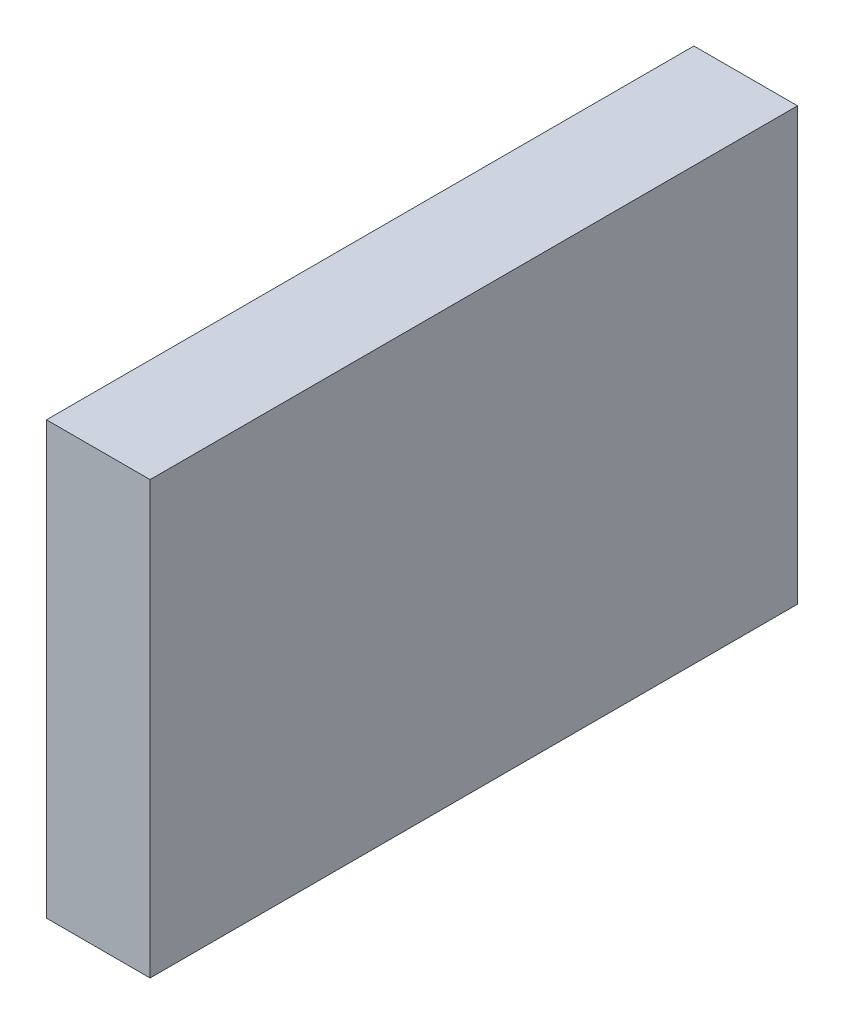
from build123d import *

# Parameters (mm, degrees)
SKETCH1_W           = 76.2
SKETCH1_H           = 50.8
BOSS_EXTRUDE1_DEPTH = 12.7
CHAMFER1_SIZE       = 0.508


with BuildPart() as part:
    # Sketch1 → Boss-Extrude1 (new body)
    with BuildSketch(Plane(origin=(0, 0, 0), x_dir=(0, 0, -1), z_dir=(1, 0, 0))):
        Rectangle(SKETCH1_W, SKETCH1_H)
    extrude(amount=BOSS_EXTRUDE1_DEPTH)

    # Chamfer1
    chamfer1_edges = [part.edges().sort_by_distance(p)[0] for p in [
        (0, -25.4, 0),
        (0, 0, -38.1),
        (0, 0, 38.1),
        (0, 25.4, 0),
    ]]
    chamfer(chamfer1_edges, length=CHAMFER1_SIZE)


solid = part.part
